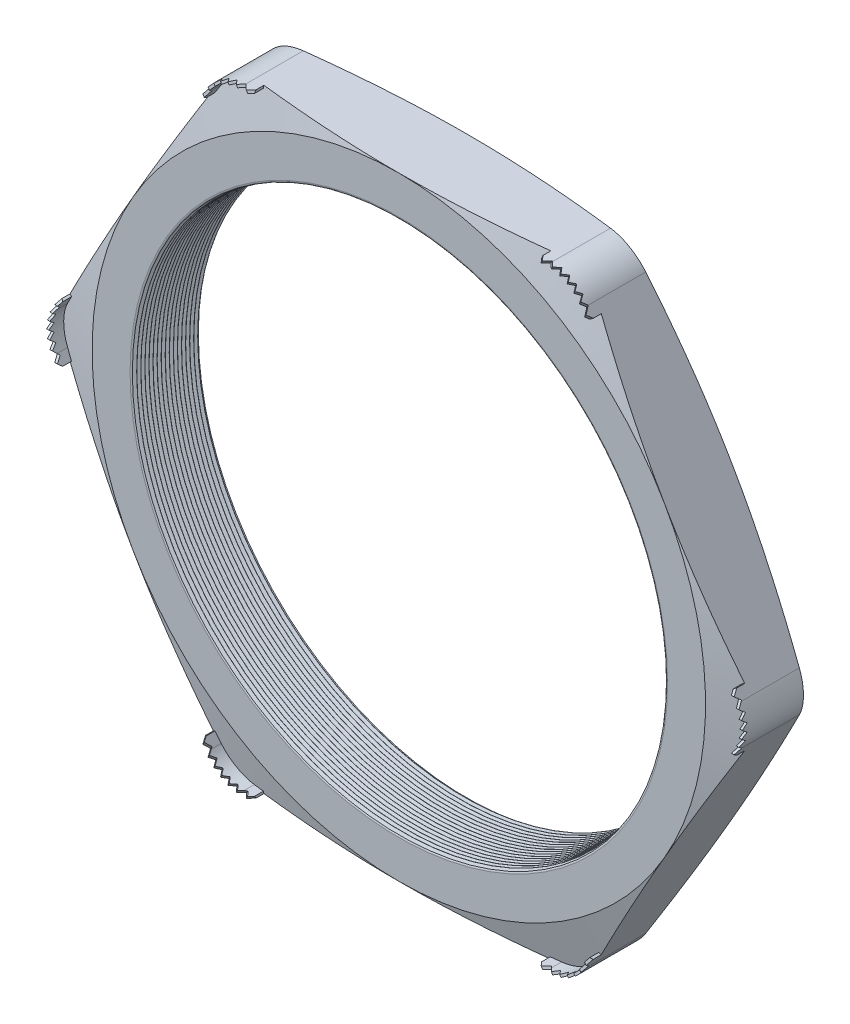
from build123d import *

# Parameters (mm, degrees)
SKETCH1_R          = 19.939
EXTRUDE1_DEPTH     = 5.08
FILLET1_R          = 3.048
FILLET3_R          = 0.2032
LPATTERN1_COUNT    = 17
LPATTERN1_PITCH    = 0.3048
SKETCH4_OUTSIDE_W  = 113.466
SKETCH4_OUTSIDE_H  = 107.296
SKETCH4_OUTSIDE_R  = 22.987
CUT_EXTRUDE1_DEPTH = 6.08
CUT_EXTRUDE1_DRAFT = -75
SKETCH5_OUTSIDE_W  = 113.466
SKETCH5_OUTSIDE_H  = 107.296
SKETCH5_OUTSIDE_R  = 22.987
CUT_EXTRUDE2_DEPTH = 6.0800001
CUT_EXTRUDE2_DRAFT = -75
EXTRUDE2_START     = -0.826509
EXTRUDE2_DEPTH     = 1.715509
CUT_EXTRUDE4_DEPTH = 8.814872962
CIRPATTERN1_COUNT  = 6
CIRPATTERN2_COUNT  = 6


with BuildPart() as part:
    # Sketch1 → Extrude1 (new body)
    with BuildSketch(Plane.XY):
        Polygon((-26.543101276, 0), (-13.271550638, -22.987), (13.271550638, -22.987), (26.543101276, 0), (13.271550638, 22.987), (-13.271550638, 22.987), align=None)
        Circle(SKETCH1_R, mode=Mode.SUBTRACT)
    extrude(amount=EXTRUDE1_DEPTH)

    # Fillet1
    fillet1_edges = [part.edges().sort_by_distance(p)[0] for p in [
        (26.543101276, 0, 2.54),
        (13.271550638, -22.987, 2.54),
        (-13.271550638, -22.987, 2.54),
        (-26.543101276, 0, 2.54),
        (-13.271550638, 22.987, 2.54),
        (13.271550638, 22.987, 2.54),
    ]]
    fillet(fillet1_edges, radius=FILLET1_R)

    # Fillet3
    fillet3_edges = [part.edges().sort_by_distance(p)[0] for p in [
        (-19.939, 0, 0),
        (-19.939, 0, 5.08),
    ]]
    fillet(fillet3_edges, radius=FILLET3_R)

    # Sketch3 → Cut-Revolve1 (revolve, cut)
    with BuildSketch(Plane(origin=(0, 0, 0), x_dir=(1, 0, 0), z_dir=(0, 1, 0))):
        Polygon((-19.939, -5.08), (-19.939, -4.786706063), (-20.193, -4.933353032), align=None)
    cut_revolve1 = revolve(axis=Axis((0, 0, 5.08), (0, 0, -1)), mode=Mode.SUBTRACT)

    # LPattern1: Cut-Revolve1 ×17
    with Locations(*[(0, 0, -i * LPATTERN1_PITCH) for i in range(1, LPATTERN1_COUNT)]):
        add(cut_revolve1, mode=Mode.SUBTRACT)


with BuildPart() as cut_extrude1_tool:
    # Sketch4 outside → Cut-Extrude1 (with draft: the straight prism first)
    with BuildSketch(Plane(origin=(0, 0, 0), x_dir=(-1, 0, 0), z_dir=(0, 0, -1))):
        Rectangle(SKETCH4_OUTSIDE_W, SKETCH4_OUTSIDE_H)
        Circle(SKETCH4_OUTSIDE_R, mode=Mode.SUBTRACT)
    extrude(amount=-CUT_EXTRUDE1_DEPTH)
    # Cut-Extrude1: the draft: its side faces are tilted about the plane it starts from
    cut_extrude1_sides = [cut_extrude1_tool.faces().sort_by_distance(p)[0] for p in [
        (0, -53.648, 3.04),
        (-56.733, 0, 3.04),
        (0, 53.648, 3.04),
        (56.733, 0, 3.04),
        (22.987, 0, 3.04),
    ]]
    draft(cut_extrude1_sides, Plane(origin=(0, 0, 0), x_dir=(-1, 0, 0), z_dir=(0, 0, -1)), CUT_EXTRUDE1_DRAFT)


with BuildPart() as part_1:
    add(part.part)

    # Cut-Extrude1: cut by cut_extrude1_tool
    add(cut_extrude1_tool.part, mode=Mode.SUBTRACT)


with BuildPart() as cut_extrude2_tool:
    # Sketch5 outside → Cut-Extrude2 (with draft: the straight prism first)
    with BuildSketch(Plane.XY.offset(5.08)):
        Rectangle(SKETCH5_OUTSIDE_W, SKETCH5_OUTSIDE_H)
        Circle(SKETCH5_OUTSIDE_R, mode=Mode.SUBTRACT)
    extrude(amount=-CUT_EXTRUDE2_DEPTH)
    # Cut-Extrude2: the draft: its side faces are tilted about the plane it starts from
    cut_extrude2_sides = [cut_extrude2_tool.faces().sort_by_distance(p)[0] for p in [
        (0, -53.648, 2.03999995),
        (56.733, 0, 2.03999995),
        (0, 53.648, 2.03999995),
        (-56.733, 0, 2.03999995),
        (-22.987, 0, 2.03999995),
    ]]
    draft(cut_extrude2_sides, Plane.XY.offset(5.08), CUT_EXTRUDE2_DRAFT)


with BuildPart() as part_2:
    add(part_1.part)

    # Cut-Extrude2: cut by cut_extrude2_tool
    add(cut_extrude2_tool.part, mode=Mode.SUBTRACT)

    # Sketch2 → Extrude2 (add)
    with BuildSketch(Plane.XY.offset(5.08).offset(EXTRUDE2_START)):
        with BuildLine():
            Line((-11.511787017, 22.987), (-10.749787017, 22.987))
            Line((-10.749787017, 22.987), (-10.749787017, 22.8092))
            Line((-10.749787017, 22.8092), (-11.511787017, 22.8092))
            ThreePointArc((-11.511787017, 22.8092), (-12.946887017, 22.424666114), (-13.997453131, 21.3741))
            Line((-13.997453131, 21.3741), (-14.378453131, 20.714188642))
            Line((-14.378453131, 20.714188642), (-14.532432448, 20.803088642))
            Line((-14.532432448, 20.803088642), (-14.151432448, 21.463))
            ThreePointArc((-14.151432448, 21.463), (-13.035787017, 22.578645431), (-11.511787017, 22.987))
        make_face()
    extrude2 = extrude(amount=EXTRUDE2_DEPTH)

    # Sketch7 → Cut-Extrude4 (cut, through all)
    with BuildSketch(Plane(origin=(-12.564120074, 21.761694321, 0), x_dir=(0.866025404, 0.5, 0), z_dir=(0.5, -0.866025404, 0))):
        Polygon((-2.183911358, 5.03555), (-1.879111358, 5.40893), (-1.574311358, 5.03555), (-1.2192, 5.40893), (-0.9144, 5.03555), (-0.6096, 5.40893), (-0.3048, 5.03555), (0, 5.40893), (0.3048, 5.03555), (0.6096, 5.40893), (0.9144, 5.03555), (1.2192, 5.40893), (1.524, 5.03555), (1.879111358, 5.40893), (2.183911358, 5.03555), (2.183911358, 5.969), (-2.183911358, 5.969), align=None)
    cut_extrude4 = extrude(amount=-CUT_EXTRUDE4_DEPTH, mode=Mode.SUBTRACT)

    # CirPattern1: Extrude2 ×6 about axis
    cirpattern1_axis = Axis((0, 0, 0), (0, 0, 1))
    for i in range(1, CIRPATTERN1_COUNT):
        add(extrude2.rotate(cirpattern1_axis, i * 360 / CIRPATTERN1_COUNT))

    # CirPattern2: Cut-Extrude4 ×6 about axis
    cirpattern2_axis = Axis((0, 0, 0), (0, 0, 1))
    for i in range(1, CIRPATTERN2_COUNT):
        add(cut_extrude4.rotate(cirpattern2_axis, i * 360 / CIRPATTERN2_COUNT), mode=Mode.SUBTRACT)


solid = part_2.part
